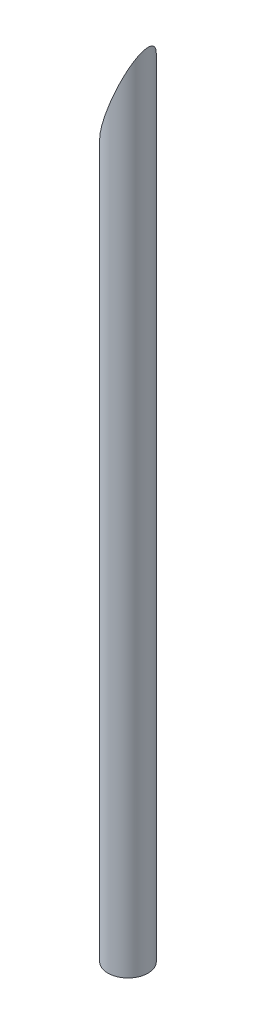
from build123d import *

# Parameters (mm, degrees)
SKETCH_1_R          = 0.15
EXTRUDE_1_DEPTH     = 6
CUT_EXTRUDE_1_DEPTH = 3


with BuildPart() as part:
    # 草图1 → 凸台-拉伸1 (new body)
    with BuildSketch(Plane(origin=(0, 0, 0), x_dir=(1, 0, 0), z_dir=(0, 1, 0))):
        Circle(SKETCH_1_R)
    extrude(amount=EXTRUDE_1_DEPTH)

    # 草图2 → 切除-拉伸1 (cut, symmetric)
    with BuildSketch(Plane.XY):
        Polygon((0.15, 6), (-0.15, 5.218962278), (-0.15, 6), align=None)
    extrude(amount=CUT_EXTRUDE_1_DEPTH, both=True, mode=Mode.SUBTRACT)


solid = part.part
